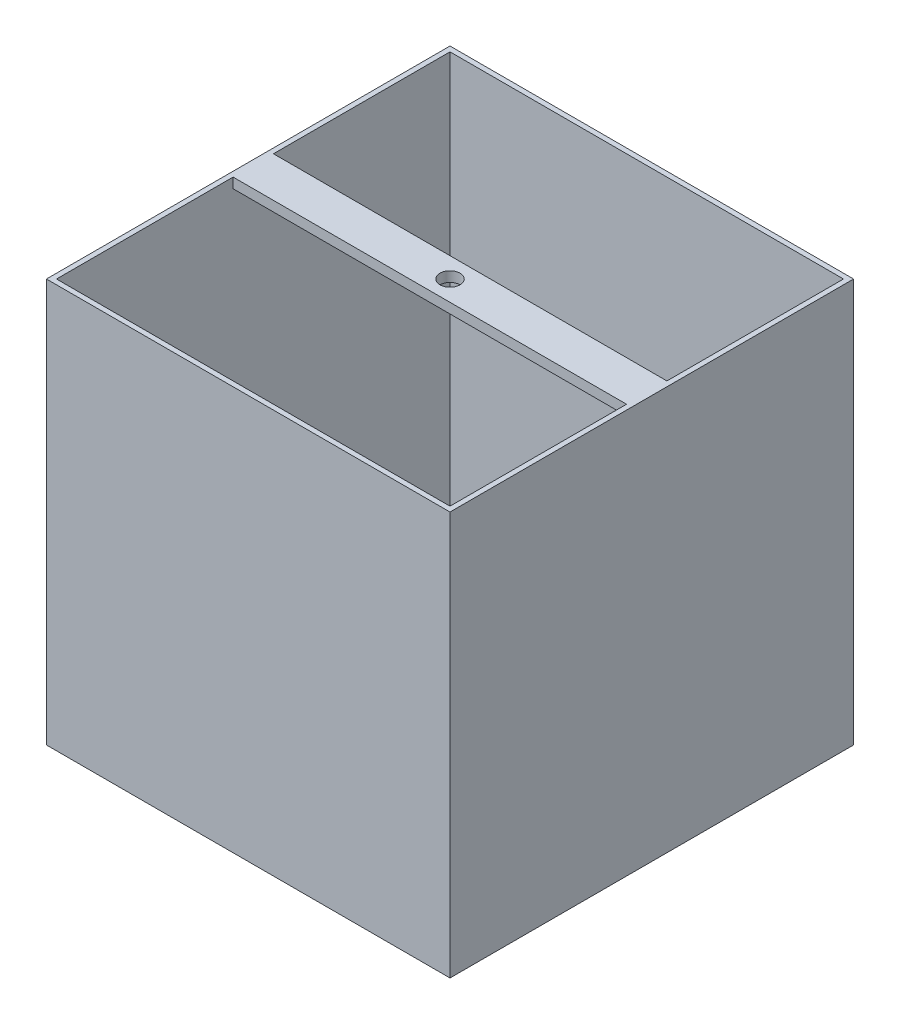
from build123d import *

# Parameters (mm, degrees)
SKETCH1_W           = 254
SKETCH1_H           = 254
BOSS_EXTRUDE1_DEPTH = 254
SKETCH2_W           = 247.65
SKETCH2_H           = 247.65
CUT_EXTRUDE1_DEPTH  = 247.65
SKETCH3_R           = 6.35
CUT_EXTRUDE2_DEPTH  = 247.65
SKETCH4_W           = 247.65
SKETCH4_H           = 25.4
SKETCH4_R           = 6.35
BOSS_EXTRUDE2_DEPTH = 6.35


with BuildPart() as part:
    # Sketch1 → Boss-Extrude1 (new body)
    with BuildSketch(Plane(origin=(0, 0, 0), x_dir=(1, 0, 0), z_dir=(0, 1, 0))):
        Rectangle(SKETCH1_W, SKETCH1_H)
    extrude(amount=BOSS_EXTRUDE1_DEPTH)

    # Sketch2 → Cut-Extrude1 (cut)
    with BuildSketch(Plane(origin=(0, 254, 0), x_dir=(1, 0, 0), z_dir=(0, 1, 0))):
        Rectangle(SKETCH2_W, SKETCH2_H)
    extrude(amount=-CUT_EXTRUDE1_DEPTH, mode=Mode.SUBTRACT)

    # Sketch3 → Cut-Extrude2 (cut)
    with BuildSketch(Plane(origin=(0, 6.35, 0), x_dir=(1, 0, 0), z_dir=(0, 1, 0))):
        Circle(SKETCH3_R)
    extrude(amount=-CUT_EXTRUDE2_DEPTH, mode=Mode.SUBTRACT)

    # Sketch4 → Boss-Extrude2 (add)
    with BuildSketch(Plane(origin=(0, 254, 0), x_dir=(1, 0, 0), z_dir=(0, 1, 0))):
        Rectangle(SKETCH4_W, SKETCH4_H)
        Circle(SKETCH4_R, mode=Mode.SUBTRACT)
    extrude(amount=-BOSS_EXTRUDE2_DEPTH)


solid = part.part
